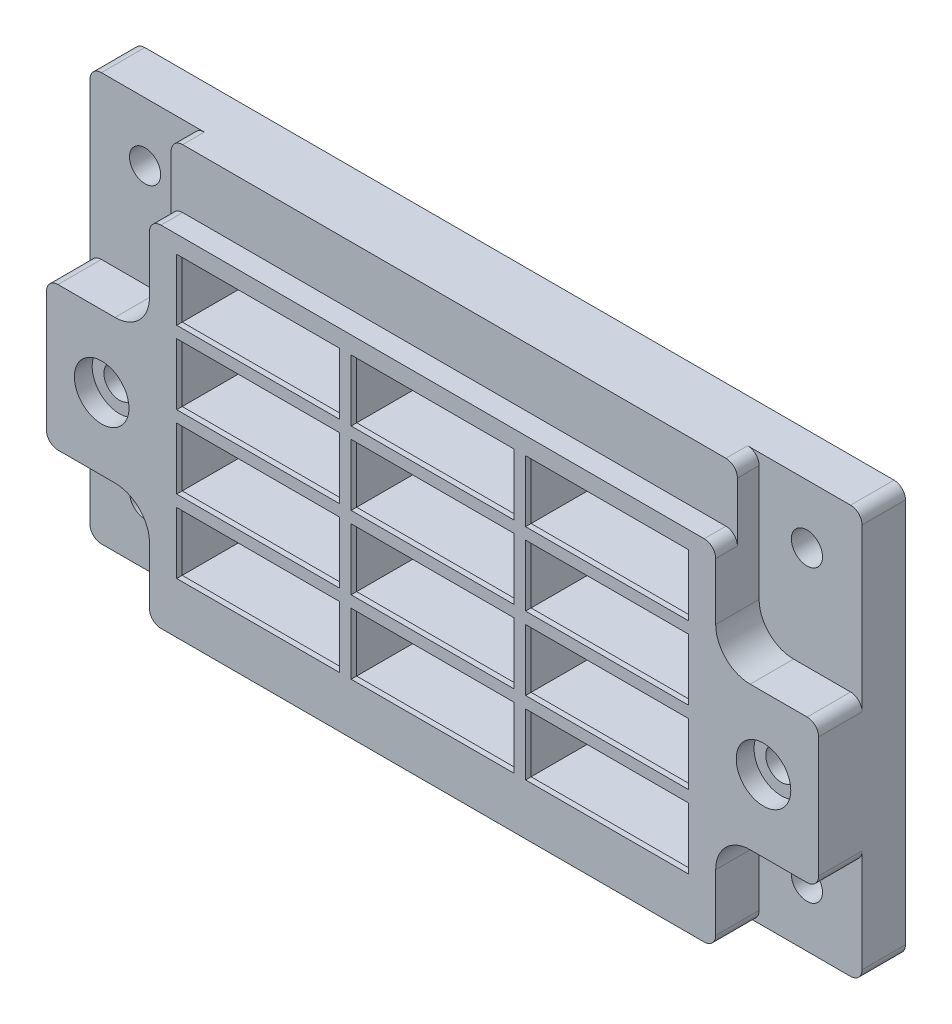
from build123d import *

# Parameters (mm, degrees)
BOSS_EXTRUDE1_DEPTH                             = 6
BOSS_EXTRUDE2_DEPTH                             = 3
BOSS_EXTRUDE3_DEPTH                             = 3
SKETCH4_W                                       = 22.5
SKETCH4_H                                       = 8.5
CUT_EXTRUDE1_DEPTH                              = 13
F_6_CLEARANCE_HOLE1_D                           = 4.3053
CBORE_FOR_6_PAN_HEAD_MACHINE_SCREW1_D           = 4.3053
CBORE_FOR_6_PAN_HEAD_MACHINE_SCREW1_CBORE_D     = 7.54126
CBORE_FOR_6_PAN_HEAD_MACHINE_SCREW1_CBORE_DEPTH = 2.4638
SKETCH10_W                                      = 23.516
SKETCH10_H                                      = 9.516
SKETCH10_W_2                                    = 22.5
SKETCH10_H_2                                    = 8.5
CUT_EXTRUDE3_DEPTH                              = 11.238
HOLE1_AT_2_COUNT                                = 2
HOLE1_AT_2_PITCH                                = 76.7868
HOLE1_AT_3_COUNT                                = 2
HOLE1_AT_3_PITCH                                = 34.736
HOLE1_AT_4_COUNT                                = 2
HOLE1_AT_4_PITCH                                = 84.278124981


with BuildPart() as part:
    # Sketch1 → Boss-Extrude1 (new body)
    with BuildSketch(Plane.XY):
        with BuildLine():
            Line((-3157.991257164, 1122.995694712), (-3054.486257164, 1122.995694712))
            ThreePointArc((-3054.486257164, 1122.995694712), (-3053.363725149, 1123.460662697), (-3052.898757164, 1124.583194712))
            Line((-3052.898757164, 1124.583194712), (-3052.898757164, 1177.796194712))
            ThreePointArc((-3052.898757164, 1177.796194712), (-3053.363725149, 1178.918726727), (-3054.486257164, 1179.383694712))
            Line((-3054.486257164, 1179.383694712), (-3157.991257164, 1179.383694712))
            ThreePointArc((-3157.991257164, 1179.383694712), (-3159.113789179, 1178.918726727), (-3159.578757164, 1177.796194712))
            Line((-3159.578757164, 1177.796194712), (-3159.578757164, 1124.583194712))
            ThreePointArc((-3159.578757164, 1124.583194712), (-3159.113789179, 1123.460662697), (-3157.991257164, 1122.995694712))
        make_face()
    extrude(amount=BOSS_EXTRUDE1_DEPTH)

    # Sketch2 → Boss-Extrude2 (add)
    with BuildSketch(Plane.XY.offset(6)):
        with BuildLine():
            Line((-3143.767257164, 1122.995694712), (-3068.710257164, 1122.995694712))
            ThreePointArc((-3068.710257164, 1122.995694712), (-3067.587725149, 1123.460662697), (-3067.122757164, 1124.583194712))
            Line((-3067.122757164, 1124.583194712), (-3067.122757164, 1132.457194712))
            ThreePointArc((-3067.122757164, 1132.457194712), (-3065.72785321, 1135.824790758), (-3062.360257164, 1137.219694712))
            Line((-3062.360257164, 1137.219694712), (-3054.486257164, 1137.219694712))
            ThreePointArc((-3054.486257164, 1137.219694712), (-3053.363725149, 1137.684662697), (-3052.898757164, 1138.807194712))
            Line((-3052.898757164, 1138.807194712), (-3052.898757164, 1155.444194712))
            ThreePointArc((-3052.898757164, 1155.444194712), (-3053.363725149, 1156.566726727), (-3054.486257164, 1157.031694712))
            Line((-3054.486257164, 1157.031694712), (-3062.360257164, 1157.031694712))
            ThreePointArc((-3062.360257164, 1157.031694712), (-3065.72785321, 1158.426598667), (-3067.122757164, 1161.794194712))
            Line((-3067.122757164, 1161.794194712), (-3067.122757164, 1169.668194712))
            Line((-3067.122757164, 1169.668194712), (-3067.122757164, 1177.796194712))
            ThreePointArc((-3067.122757164, 1177.796194712), (-3067.587725149, 1178.918726727), (-3068.710257164, 1179.383694712))
            Line((-3068.710257164, 1179.383694712), (-3143.767257164, 1179.383694712))
            ThreePointArc((-3143.767257164, 1179.383694712), (-3144.889789179, 1178.918726727), (-3145.354757164, 1177.796194712))
            Line((-3145.354757164, 1177.796194712), (-3145.354757164, 1169.668194712))
            Line((-3145.354757164, 1169.668194712), (-3145.354757164, 1161.794194712))
            ThreePointArc((-3145.354757164, 1161.794194712), (-3146.749661119, 1158.426598667), (-3150.117257164, 1157.031694712))
            Line((-3150.117257164, 1157.031694712), (-3157.991257164, 1157.031694712))
            ThreePointArc((-3157.991257164, 1157.031694712), (-3159.113789179, 1156.566726727), (-3159.578757164, 1155.444194712))
            Line((-3159.578757164, 1155.444194712), (-3159.578757164, 1138.807194712))
            ThreePointArc((-3159.578757164, 1138.807194712), (-3159.113789179, 1137.684662697), (-3157.991257164, 1137.219694712))
            Line((-3157.991257164, 1137.219694712), (-3150.117257164, 1137.219694712))
            ThreePointArc((-3150.117257164, 1137.219694712), (-3146.749661119, 1135.824790758), (-3145.354757164, 1132.457194712))
            Line((-3145.354757164, 1132.457194712), (-3145.354757164, 1124.583194712))
            ThreePointArc((-3145.354757164, 1124.583194712), (-3144.889789179, 1123.460662697), (-3143.767257164, 1122.995694712))
        make_face()
    extrude(amount=BOSS_EXTRUDE2_DEPTH)

    # Sketch3 → Boss-Extrude3 (add)
    with BuildSketch(Plane.XY.offset(9)):
        with BuildLine():
            Line((-3143.767257164, 1122.995694712), (-3068.710257164, 1122.995694712))
            ThreePointArc((-3068.710257164, 1122.995694712), (-3067.587725149, 1123.460662697), (-3067.122757164, 1124.583194712))
            Line((-3067.122757164, 1124.583194712), (-3067.122757164, 1132.457194712))
            ThreePointArc((-3067.122757164, 1132.457194712), (-3065.72785321, 1135.824790758), (-3062.360257164, 1137.219694712))
            Line((-3062.360257164, 1137.219694712), (-3054.486257164, 1137.219694712))
            ThreePointArc((-3054.486257164, 1137.219694712), (-3053.363725149, 1137.684662697), (-3052.898757164, 1138.807194712))
            Line((-3052.898757164, 1138.807194712), (-3052.898757164, 1155.444194712))
            ThreePointArc((-3052.898757164, 1155.444194712), (-3053.363725149, 1156.566726727), (-3054.486257164, 1157.031694712))
            Line((-3054.486257164, 1157.031694712), (-3062.360257164, 1157.031694712))
            ThreePointArc((-3062.360257164, 1157.031694712), (-3065.72785321, 1158.426598667), (-3067.122757164, 1161.794194712))
            Line((-3067.122757164, 1161.794194712), (-3067.122757164, 1169.668194712))
            ThreePointArc((-3067.122757164, 1169.668194712), (-3067.587725149, 1170.790726727), (-3068.710257164, 1171.255694712))
            Line((-3068.710257164, 1171.255694712), (-3143.767257164, 1171.255694712))
            ThreePointArc((-3143.767257164, 1171.255694712), (-3144.889789179, 1170.790726727), (-3145.354757164, 1169.668194712))
            Line((-3145.354757164, 1169.668194712), (-3145.354757164, 1161.794194712))
            ThreePointArc((-3145.354757164, 1161.794194712), (-3146.749661119, 1158.426598667), (-3150.117257164, 1157.031694712))
            Line((-3150.117257164, 1157.031694712), (-3157.991257164, 1157.031694712))
            ThreePointArc((-3157.991257164, 1157.031694712), (-3159.113789179, 1156.566726727), (-3159.578757164, 1155.444194712))
            Line((-3159.578757164, 1155.444194712), (-3159.578757164, 1138.807194712))
            ThreePointArc((-3159.578757164, 1138.807194712), (-3159.113789179, 1137.684662697), (-3157.991257164, 1137.219694712))
            Line((-3157.991257164, 1137.219694712), (-3150.117257164, 1137.219694712))
            ThreePointArc((-3150.117257164, 1137.219694712), (-3146.749661119, 1135.824790758), (-3145.354757164, 1132.457194712))
            Line((-3145.354757164, 1132.457194712), (-3145.354757164, 1124.583194712))
            ThreePointArc((-3145.354757164, 1124.583194712), (-3144.889789179, 1123.460662697), (-3143.767257164, 1122.995694712))
        make_face()
    extrude(amount=BOSS_EXTRUDE3_DEPTH)

    # Sketch4 → Cut-Extrude1 (cut, through all)
    with BuildSketch(Plane.XY.offset(12)):
        with Locations((-3082.138757164, 1134.305694712)):
            Rectangle(SKETCH4_W, SKETCH4_H)
        with Locations((-3106.238757164, 1134.305694712)):
            Rectangle(SKETCH4_W, SKETCH4_H)
        with Locations((-3130.338757164, 1134.305694712)):
            Rectangle(SKETCH4_W, SKETCH4_H)
        with Locations((-3130.338757164, 1144.405694712)):
            Rectangle(SKETCH4_W, SKETCH4_H)
        with Locations((-3106.238757164, 1144.405694712)):
            Rectangle(SKETCH4_W, SKETCH4_H)
        with Locations((-3082.138757164, 1144.405694712)):
            Rectangle(SKETCH4_W, SKETCH4_H)
        with Locations((-3082.138757164, 1154.505694712)):
            Rectangle(SKETCH4_W, SKETCH4_H)
        with Locations((-3106.238757164, 1154.505694712)):
            Rectangle(SKETCH4_W, SKETCH4_H)
        with Locations((-3130.338757164, 1154.505694712)):
            Rectangle(SKETCH4_W, SKETCH4_H)
        with Locations((-3130.338757164, 1164.605694712)):
            Rectangle(SKETCH4_W, SKETCH4_H)
        with Locations((-3106.238757164, 1164.605694712)):
            Rectangle(SKETCH4_W, SKETCH4_H)
        with Locations((-3082.138757164, 1164.605694712)):
            Rectangle(SKETCH4_W, SKETCH4_H)
    extrude(amount=-CUT_EXTRUDE1_DEPTH, mode=Mode.SUBTRACT)

    # #6 Clearance Hole1 (through all)
    with Locations(Plane.XY.offset(6)):
        with Locations((-3060.518757164, 1131.123694712), (-3151.958757164, 1131.123694712), (-3151.958757164, 1171.255694712), (-3060.518757164, 1171.255694712)):
            Hole(F_6_CLEARANCE_HOLE1_D / 2)

    # CBORE for #6 Pan Head Machine Screw1 (through all)
    with Locations(Plane.XY.offset(12)):
        with Locations((-3060.518757164, 1147.125694712), (-3151.958757164, 1147.125694712)):
            CounterBoreHole(CBORE_FOR_6_PAN_HEAD_MACHINE_SCREW1_D / 2, CBORE_FOR_6_PAN_HEAD_MACHINE_SCREW1_CBORE_D / 2, CBORE_FOR_6_PAN_HEAD_MACHINE_SCREW1_CBORE_DEPTH)

    # Sketch10 → Cut-Extrude3 (cut)
    with BuildSketch(Plane(origin=(0, 0, 0), x_dir=(-1, 0, 0), z_dir=(0, 0, -1))):
        with Locations((3130.338757164, 1134.305694712)):
            Rectangle(SKETCH10_W, SKETCH10_H)
        with Locations((3130.338757164, 1134.305694712)):
            Rectangle(SKETCH10_W_2, SKETCH10_H_2, mode=Mode.SUBTRACT)
        with Locations((3106.238757164, 1134.305694712)):
            Rectangle(SKETCH10_W, SKETCH10_H)
        with Locations((3106.238757164, 1134.305694712)):
            Rectangle(SKETCH10_W_2, SKETCH10_H_2, mode=Mode.SUBTRACT)
        with Locations((3082.138757164, 1134.305694712)):
            Rectangle(SKETCH10_W, SKETCH10_H)
        with Locations((3082.138757164, 1134.305694712)):
            Rectangle(SKETCH10_W_2, SKETCH10_H_2, mode=Mode.SUBTRACT)
        with Locations((3082.138757164, 1154.505694712)):
            Rectangle(SKETCH10_W, SKETCH10_H)
        with Locations((3082.138757164, 1154.505694712)):
            Rectangle(SKETCH10_W_2, SKETCH10_H_2, mode=Mode.SUBTRACT)
        with Locations((3082.138757164, 1144.405694712)):
            Rectangle(SKETCH10_W, SKETCH10_H)
        with Locations((3082.138757164, 1144.405694712)):
            Rectangle(SKETCH10_W_2, SKETCH10_H_2, mode=Mode.SUBTRACT)
        with Locations((3106.238757164, 1144.405694712)):
            Rectangle(SKETCH10_W, SKETCH10_H)
        with Locations((3106.238757164, 1144.405694712)):
            Rectangle(SKETCH10_W_2, SKETCH10_H_2, mode=Mode.SUBTRACT)
        with Locations((3130.338757164, 1144.405694712)):
            Rectangle(SKETCH10_W, SKETCH10_H)
        with Locations((3130.338757164, 1144.405694712)):
            Rectangle(SKETCH10_W_2, SKETCH10_H_2, mode=Mode.SUBTRACT)
        with Locations((3106.238757164, 1164.605694712)):
            Rectangle(SKETCH10_W, SKETCH10_H)
        with Locations((3106.238757164, 1164.605694712)):
            Rectangle(SKETCH10_W_2, SKETCH10_H_2, mode=Mode.SUBTRACT)
        with Locations((3130.338757164, 1164.605694712)):
            Rectangle(SKETCH10_W, SKETCH10_H)
        with Locations((3130.338757164, 1164.605694712)):
            Rectangle(SKETCH10_W_2, SKETCH10_H_2, mode=Mode.SUBTRACT)
        with Locations((3130.338757164, 1154.505694712)):
            Rectangle(SKETCH10_W, SKETCH10_H)
        with Locations((3130.338757164, 1154.505694712)):
            Rectangle(SKETCH10_W_2, SKETCH10_H_2, mode=Mode.SUBTRACT)
        with Locations((3106.238757164, 1154.505694712)):
            Rectangle(SKETCH10_W, SKETCH10_H)
        with Locations((3106.238757164, 1154.505694712)):
            Rectangle(SKETCH10_W_2, SKETCH10_H_2, mode=Mode.SUBTRACT)
        with Locations((3082.138757164, 1164.605694712)):
            Rectangle(SKETCH10_W, SKETCH10_H)
        with Locations((3082.138757164, 1164.605694712)):
            Rectangle(SKETCH10_W_2, SKETCH10_H_2, mode=Mode.SUBTRACT)
    extrude(amount=-CUT_EXTRUDE3_DEPTH, mode=Mode.SUBTRACT)

    # Sketch11 → Hole1 (revolve, cut)
    with BuildSketch(Plane(origin=(-3144.636757164, 1132.087694712, 0), x_dir=(0, 1, 0), z_dir=(1, 0, 0))):
        Polygon((0, 0), (0, 2.921), (1.4986, 2.921), (1.6383, 0), align=None)
    hole1 = revolve(axis=Axis((-3144.636757164, 1132.087694712, 110), (0, 0, -1)), mode=Mode.SUBTRACT)

    # Hole1 at 2: Hole1 ×2
    with Locations(*[(i * HOLE1_AT_2_PITCH, 0, 0) for i in range(1, HOLE1_AT_2_COUNT)]):
        add(hole1, mode=Mode.SUBTRACT)

    # Hole1 at 3: Hole1 ×2
    with Locations(*[(0, i * HOLE1_AT_3_PITCH, 0) for i in range(1, HOLE1_AT_3_COUNT)]):
        add(hole1, mode=Mode.SUBTRACT)

    # Hole1 at 4: Hole1 ×2
    with Locations(*[Vector(0.911111869, 0.412159146, 0) * (i * HOLE1_AT_4_PITCH) for i in range(1, HOLE1_AT_4_COUNT)]):
        add(hole1, mode=Mode.SUBTRACT)


solid = part.part
